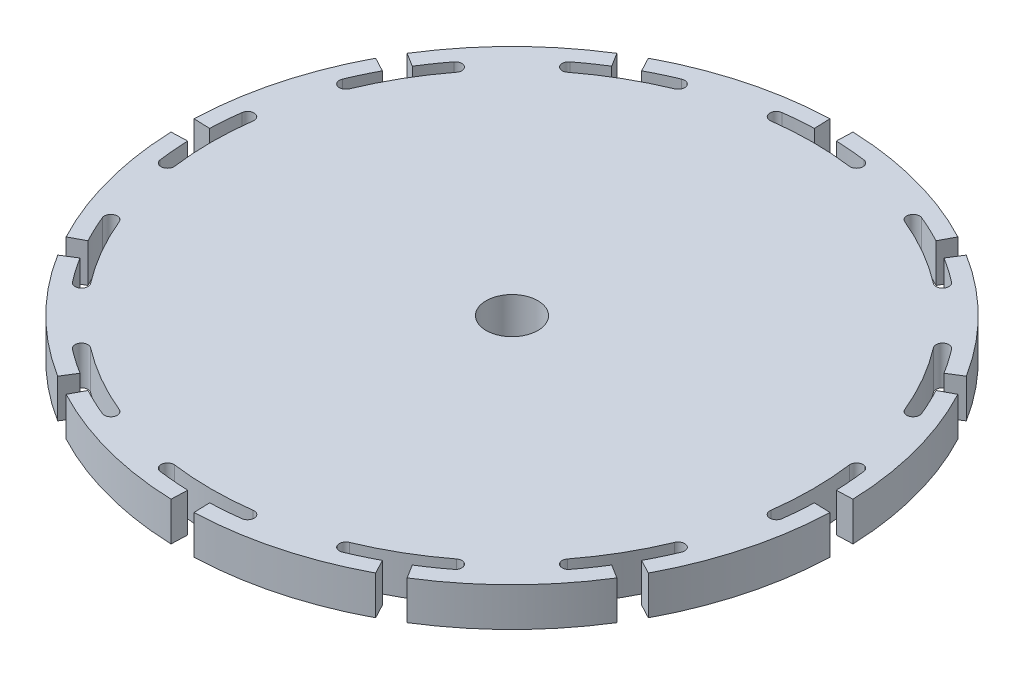
from build123d import *

# Parameters (mm, degrees)
SKETCH1_R           = 51
BOSS_EXTRUDE1_DEPTH = 6
CUT_EXTRUDE1_DEPTH  = 7
SKETCH3_R           = 4
CUT_EXTRUDE2_DEPTH  = 6


with BuildPart() as part:
    # Sketch1 → Boss-Extrude1 (new body)
    with BuildSketch(Plane(origin=(0, 0, 0), x_dir=(1, 0, 0), z_dir=(0, 1, 0))):
        Circle(SKETCH1_R)
    extrude(amount=BOSS_EXTRUDE1_DEPTH)

    # Sketch2 → Cut-Extrude1 (cut, through all)
    with BuildSketch(Plane(origin=(0, 0, 0), x_dir=(1, 0, 0), z_dir=(0, 1, 0))):
        with BuildLine():
            Line((-1.779874332, 50.968932178), (-1.69262559, 48.47045511))
            ThreePointArc((-1.69262559, 48.47045511), (-4.016198064, 48.333426871), (-6.330520323, 48.085075777))
            ThreePointArc((-6.330520323, 48.085075777), (-7.191438992, 46.963104723), (-6.069467938, 46.102186054))
            ThreePointArc((-6.069467938, 46.102186054), (0, 46.5), (6.069467938, 46.102186054))
            ThreePointArc((6.069467938, 46.102186054), (7.191438992, 46.963104723), (6.330520323, 48.085075777))
            ThreePointArc((6.330520323, 48.085075777), (4.016198064, 48.333426871), (1.69262559, 48.47045511))
            Line((1.69262559, 48.47045511), (1.779874332, 50.968932178))
            ThreePointArc((1.779874332, 50.968932178), (0, 51), (-1.779874332, 50.968932178))
        make_face()
        with BuildLine():
            Line((23.943049702, 45.030327236), (22.769370795, 42.822958254))
            ThreePointArc((22.769370795, 42.822958254), (20.688583885, 43.866074555), (18.56014647, 44.808157327))
            ThreePointArc((18.56014647, 44.808157327), (17.253583505, 44.266961227), (17.794779605, 42.960398262))
            ThreePointArc((17.794779605, 42.960398262), (23.25, 40.270181276), (28.307406449, 36.890930324))
            ThreePointArc((28.307406449, 36.890930324), (29.709521218, 37.075522235), (29.524929307, 38.477637004))
            ThreePointArc((29.524929307, 38.477637004), (27.644842986, 39.84987649), (25.701084315, 41.130332664))
            Line((25.701084315, 41.130332664), (27.025882476, 43.250452904))
            ThreePointArc((27.025882476, 43.250452904), (25.5, 44.167295593), (23.943049702, 45.030327236))
        make_face()
        with BuildLine():
            Line((43.250452904, 27.025882476), (41.130332664, 25.701084315))
            ThreePointArc((41.130332664, 25.701084315), (39.84987649, 27.644842986), (38.477637004, 29.524929307))
            ThreePointArc((38.477637004, 29.524929307), (37.075522235, 29.709521218), (36.890930324, 28.307406449))
            ThreePointArc((36.890930324, 28.307406449), (40.270181276, 23.25), (42.960398262, 17.794779605))
            ThreePointArc((42.960398262, 17.794779605), (44.266961227, 17.253583505), (44.808157327, 18.56014647))
            ThreePointArc((44.808157327, 18.56014647), (43.866074555, 20.688583885), (42.822958254, 22.769370795))
            Line((42.822958254, 22.769370795), (45.030327236, 23.943049702))
            ThreePointArc((45.030327236, 23.943049702), (44.167295593, 25.5), (43.250452904, 27.025882476))
        make_face()
        with BuildLine():
            Line((50.968932178, 1.779874332), (48.47045511, 1.69262559))
            ThreePointArc((48.47045511, 1.69262559), (48.333426871, 4.016198064), (48.085075777, 6.330520323))
            ThreePointArc((48.085075777, 6.330520323), (46.963104723, 7.191438992), (46.102186054, 6.069467938))
            ThreePointArc((46.102186054, 6.069467938), (46.5, 0), (46.102186054, -6.069467938))
            ThreePointArc((46.102186054, -6.069467938), (46.963104723, -7.191438992), (48.085075777, -6.330520323))
            ThreePointArc((48.085075777, -6.330520323), (48.333426871, -4.016198064), (48.47045511, -1.69262559))
            Line((48.47045511, -1.69262559), (50.968932178, -1.779874332))
            ThreePointArc((50.968932178, -1.779874332), (51, 0), (50.968932178, 1.779874332))
        make_face()
        with BuildLine():
            Line((45.030327236, -23.943049702), (42.822958254, -22.769370795))
            ThreePointArc((42.822958254, -22.769370795), (43.866074555, -20.688583885), (44.808157327, -18.56014647))
            ThreePointArc((44.808157327, -18.56014647), (44.266961227, -17.253583505), (42.960398262, -17.794779605))
            ThreePointArc((42.960398262, -17.794779605), (40.270181276, -23.25), (36.890930324, -28.307406449))
            ThreePointArc((36.890930324, -28.307406449), (37.075522235, -29.709521218), (38.477637004, -29.524929307))
            ThreePointArc((38.477637004, -29.524929307), (39.84987649, -27.644842986), (41.130332664, -25.701084315))
            Line((41.130332664, -25.701084315), (43.250452904, -27.025882476))
            ThreePointArc((43.250452904, -27.025882476), (44.167295593, -25.5), (45.030327236, -23.943049702))
        make_face()
        with BuildLine():
            Line((27.025882476, -43.250452904), (25.701084315, -41.130332664))
            ThreePointArc((25.701084315, -41.130332664), (27.644842986, -39.84987649), (29.524929307, -38.477637004))
            ThreePointArc((29.524929307, -38.477637004), (29.709521218, -37.075522235), (28.307406449, -36.890930324))
            ThreePointArc((28.307406449, -36.890930324), (23.25, -40.270181276), (17.794779605, -42.960398262))
            ThreePointArc((17.794779605, -42.960398262), (17.253583505, -44.266961227), (18.56014647, -44.808157327))
            ThreePointArc((18.56014647, -44.808157327), (20.688583885, -43.866074555), (22.769370795, -42.822958254))
            Line((22.769370795, -42.822958254), (23.943049702, -45.030327236))
            ThreePointArc((23.943049702, -45.030327236), (25.5, -44.167295593), (27.025882476, -43.250452904))
        make_face()
        with BuildLine():
            Line((1.779874332, -50.968932178), (1.69262559, -48.47045511))
            ThreePointArc((1.69262559, -48.47045511), (4.016198064, -48.333426871), (6.330520323, -48.085075777))
            ThreePointArc((6.330520323, -48.085075777), (7.191438992, -46.963104723), (6.069467938, -46.102186054))
            ThreePointArc((6.069467938, -46.102186054), (0, -46.5), (-6.069467938, -46.102186054))
            ThreePointArc((-6.069467938, -46.102186054), (-7.191438992, -46.963104723), (-6.330520323, -48.085075777))
            ThreePointArc((-6.330520323, -48.085075777), (-4.016198064, -48.333426871), (-1.69262559, -48.47045511))
            Line((-1.69262559, -48.47045511), (-1.779874332, -50.968932178))
            ThreePointArc((-1.779874332, -50.968932178), (0, -51), (1.779874332, -50.968932178))
        make_face()
        with BuildLine():
            Line((-23.943049702, -45.030327236), (-22.769370795, -42.822958254))
            ThreePointArc((-22.769370795, -42.822958254), (-20.688583885, -43.866074555), (-18.56014647, -44.808157327))
            ThreePointArc((-18.56014647, -44.808157327), (-17.253583505, -44.266961227), (-17.794779605, -42.960398262))
            ThreePointArc((-17.794779605, -42.960398262), (-23.25, -40.270181276), (-28.307406449, -36.890930324))
            ThreePointArc((-28.307406449, -36.890930324), (-29.709521218, -37.075522235), (-29.524929307, -38.477637004))
            ThreePointArc((-29.524929307, -38.477637004), (-27.644842986, -39.84987649), (-25.701084315, -41.130332664))
            Line((-25.701084315, -41.130332664), (-27.025882476, -43.250452904))
            ThreePointArc((-27.025882476, -43.250452904), (-25.5, -44.167295593), (-23.943049702, -45.030327236))
        make_face()
        with BuildLine():
            Line((-43.250452904, -27.025882476), (-41.130332664, -25.701084315))
            ThreePointArc((-41.130332664, -25.701084315), (-39.84987649, -27.644842986), (-38.477637004, -29.524929307))
            ThreePointArc((-38.477637004, -29.524929307), (-37.075522235, -29.709521218), (-36.890930324, -28.307406449))
            ThreePointArc((-36.890930324, -28.307406449), (-40.270181276, -23.25), (-42.960398262, -17.794779605))
            ThreePointArc((-42.960398262, -17.794779605), (-44.266961227, -17.253583505), (-44.808157327, -18.56014647))
            ThreePointArc((-44.808157327, -18.56014647), (-43.866074555, -20.688583885), (-42.822958254, -22.769370795))
            Line((-42.822958254, -22.769370795), (-45.030327236, -23.943049702))
            ThreePointArc((-45.030327236, -23.943049702), (-44.167295593, -25.5), (-43.250452904, -27.025882476))
        make_face()
        with BuildLine():
            Line((-50.968932178, -1.779874332), (-48.47045511, -1.69262559))
            ThreePointArc((-48.47045511, -1.69262559), (-48.333426871, -4.016198064), (-48.085075777, -6.330520323))
            ThreePointArc((-48.085075777, -6.330520323), (-46.963104723, -7.191438992), (-46.102186054, -6.069467938))
            ThreePointArc((-46.102186054, -6.069467938), (-46.5, 0), (-46.102186054, 6.069467938))
            ThreePointArc((-46.102186054, 6.069467938), (-46.963104723, 7.191438992), (-48.085075777, 6.330520323))
            ThreePointArc((-48.085075777, 6.330520323), (-48.333426871, 4.016198064), (-48.47045511, 1.69262559))
            Line((-48.47045511, 1.69262559), (-50.968932178, 1.779874332))
            ThreePointArc((-50.968932178, 1.779874332), (-51, 0), (-50.968932178, -1.779874332))
        make_face()
        with BuildLine():
            Line((-45.030327236, 23.943049702), (-42.822958254, 22.769370795))
            ThreePointArc((-42.822958254, 22.769370795), (-43.866074555, 20.688583885), (-44.808157327, 18.56014647))
            ThreePointArc((-44.808157327, 18.56014647), (-44.266961227, 17.253583505), (-42.960398262, 17.794779605))
            ThreePointArc((-42.960398262, 17.794779605), (-40.270181276, 23.25), (-36.890930324, 28.307406449))
            ThreePointArc((-36.890930324, 28.307406449), (-37.075522235, 29.709521218), (-38.477637004, 29.524929307))
            ThreePointArc((-38.477637004, 29.524929307), (-39.84987649, 27.644842986), (-41.130332664, 25.701084315))
            Line((-41.130332664, 25.701084315), (-43.250452904, 27.025882476))
            ThreePointArc((-43.250452904, 27.025882476), (-44.167295593, 25.5), (-45.030327236, 23.943049702))
        make_face()
        with BuildLine():
            Line((-27.025882476, 43.250452904), (-25.701084315, 41.130332664))
            ThreePointArc((-25.701084315, 41.130332664), (-27.644842986, 39.84987649), (-29.524929307, 38.477637004))
            ThreePointArc((-29.524929307, 38.477637004), (-29.709521218, 37.075522235), (-28.307406449, 36.890930324))
            ThreePointArc((-28.307406449, 36.890930324), (-23.25, 40.270181276), (-17.794779605, 42.960398262))
            ThreePointArc((-17.794779605, 42.960398262), (-17.253583505, 44.266961227), (-18.56014647, 44.808157327))
            ThreePointArc((-18.56014647, 44.808157327), (-20.688583885, 43.866074555), (-22.769370795, 42.822958254))
            Line((-22.769370795, 42.822958254), (-23.943049702, 45.030327236))
            ThreePointArc((-23.943049702, 45.030327236), (-25.5, 44.167295593), (-27.025882476, 43.250452904))
        make_face()
    extrude(amount=CUT_EXTRUDE1_DEPTH, mode=Mode.SUBTRACT)

    # Sketch3 → Cut-Extrude2 (cut)
    with BuildSketch(Plane(origin=(0, 0, 0), x_dir=(1, 0, 0), z_dir=(0, 1, 0))):
        Circle(SKETCH3_R)
    extrude(amount=CUT_EXTRUDE2_DEPTH, mode=Mode.SUBTRACT)


solid = part.part
